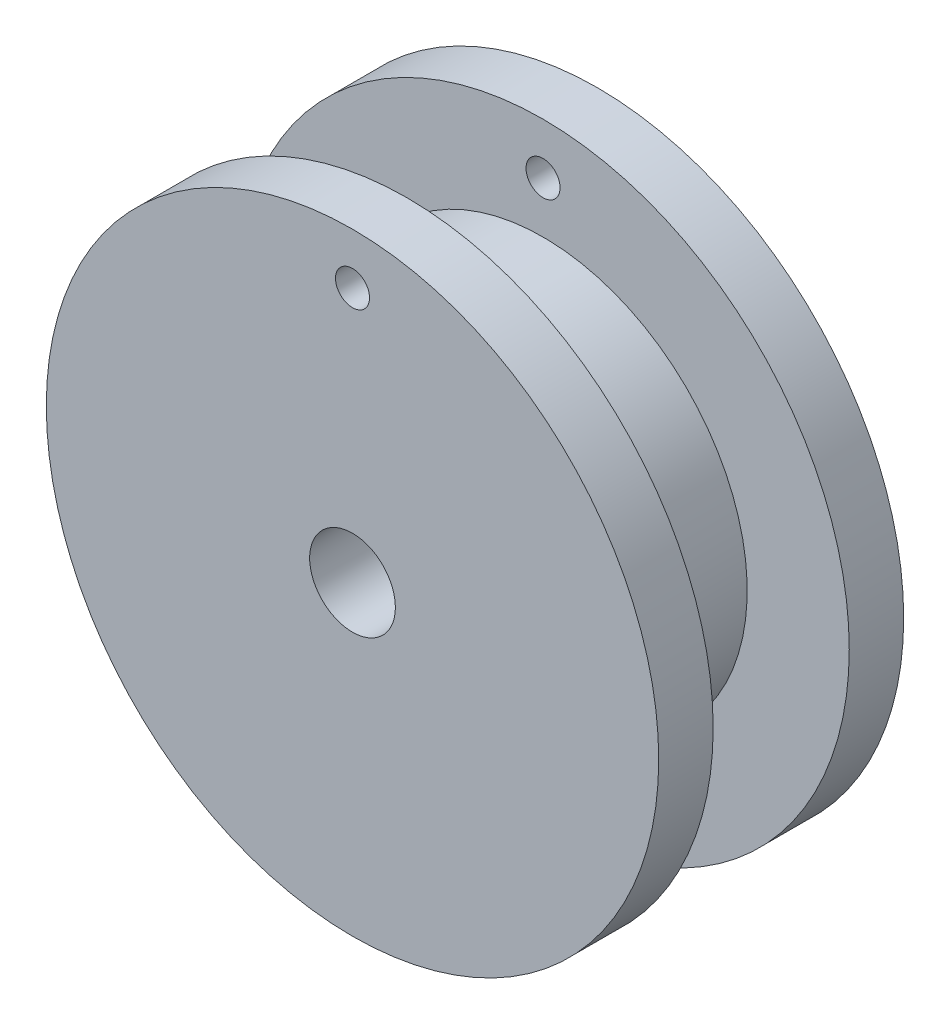
from build123d import *

# Parameters (mm, degrees)
SKETCH1_R           = 9.525
BOSS_EXTRUDE1_DEPTH = 6.35
SKETCH2_R           = 2
CUT_EXTRUDE1_DEPTH  = 15.892070037
SKETCH5_R           = 14.2875
SKETCH5_R_2         = 2
BOSS_EXTRUDE3_DEPTH = 2.54
SKETCH6_R           = 14.2875
SKETCH6_R_2         = 2
BOSS_EXTRUDE4_DEPTH = 2.54
SKETCH7_R           = 0.79375
CUT_EXTRUDE2_DEPTH  = 24.214439741


with BuildPart() as part:
    # Sketch1 → Boss-Extrude1 (new body)
    with BuildSketch(Plane.XY):
        Circle(SKETCH1_R)
    extrude(amount=BOSS_EXTRUDE1_DEPTH)

    # Sketch2 → Cut-Extrude1 (cut, through all)
    with BuildSketch(Plane.XY.offset(6.35)):
        Circle(SKETCH2_R)
    extrude(amount=-CUT_EXTRUDE1_DEPTH, mode=Mode.SUBTRACT)

    # Sketch5 → Boss-Extrude3 (add)
    with BuildSketch(Plane.XY.offset(6.35)):
        Circle(SKETCH5_R)
        Circle(SKETCH5_R_2, mode=Mode.SUBTRACT)
    extrude(amount=BOSS_EXTRUDE3_DEPTH)

    # Sketch6 → Boss-Extrude4 (add)
    with BuildSketch(Plane(origin=(0, 0, 0), x_dir=(-1, 0, 0), z_dir=(0, 0, -1))):
        with Locations(Location((0, 0, 0), (0, 0, 180))):
            Circle(SKETCH6_R)
        with Locations(Location((0, 0, 0), (0, 0, 180))):
            Circle(SKETCH6_R_2, mode=Mode.SUBTRACT)
    extrude(amount=BOSS_EXTRUDE4_DEPTH)

    # Sketch7 → Cut-Extrude2 (cut, through all)
    with BuildSketch(Plane.XY.offset(8.89)):
        with Locations((0, 11.90625)):
            Circle(SKETCH7_R)
    extrude(amount=-CUT_EXTRUDE2_DEPTH, mode=Mode.SUBTRACT)


solid = part.part
